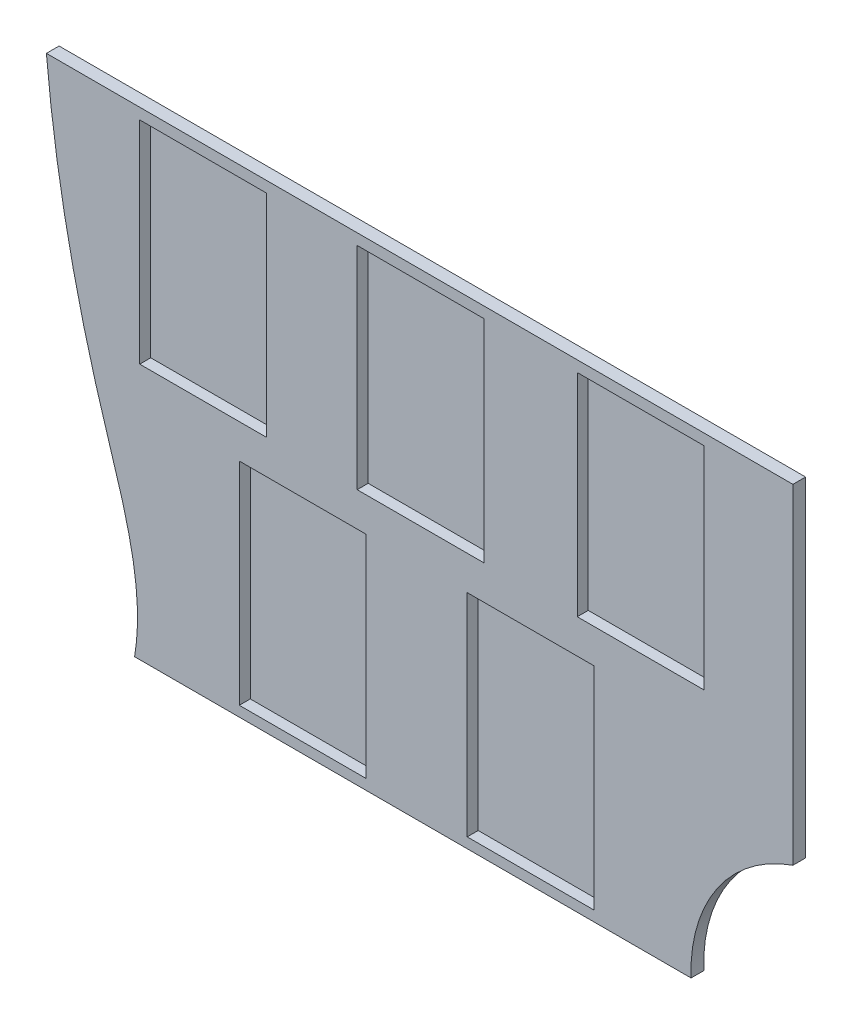
from build123d import *

# Parameters (mm, degrees)
BOSS_EXTRUDE1_DEPTH = 1.5
SKETCH2_W           = 144.766923913
SKETCH2_H           = 30.83722243
CUT_EXTRUDE1_DEPTH  = 65.5
SKETCH3_W           = 15
SKETCH3_H           = 25
CUT_EXTRUDE2_DEPTH  = 1.3


with BuildPart() as part:
    # Sketch1 → Boss-Extrude1 (new body)
    with BuildSketch(Plane.XY):
        with BuildLine():
            Line((0, 0), (65.76731, 0))
            ThreePointArc((65.76731, 0), (68.890778194, 10.762295293), (77.804111714, 17.55461))
            Line((77.804111714, 17.55461), (77.804111714, 76.07506))
            Line((77.804111714, 76.07506), (-10.924558286, 76.07506))
            add(Edge.make_bspline(
                [(-10.924558286, 76.07506), (-11.335216037, 65.701051621), (-10.134883802, 47.610493724), (-4.204795631, 22.570600883), (1.324592934, 7.942603507), (0, 0)],
                knots=[0, 0, 0, 0, 0.403327981, 0.698479283, 1, 1, 1, 1], degree=3))
        make_face()
    extrude(amount=BOSS_EXTRUDE1_DEPTH)

    # Sketch2 → Cut-Extrude1 (cut)
    with BuildSketch(Plane.XY.offset(11.5)):
        with Locations((32.739385879, 71.968611215)):
            Rectangle(SKETCH2_W, SKETCH2_H)
    extrude(amount=-CUT_EXTRUDE1_DEPTH, mode=Mode.SUBTRACT)

    # Sketch3 → Cut-Extrude2 (cut)
    with BuildSketch(Plane.XY.offset(1.5)):
        with Locations((8.104747285, 42.750740974)):
            Rectangle(SKETCH3_W, SKETCH3_H)
        with Locations((33.805332754, 42.750740974)):
            Rectangle(SKETCH3_W, SKETCH3_H)
        with Locations((59.815563831, 42.750740974)):
            Rectangle(SKETCH3_W, SKETCH3_H)
        with Locations((19.871280391, 13.717582368)):
            Rectangle(SKETCH3_W, SKETCH3_H)
        with Locations((46.810448292, 13.717582368)):
            Rectangle(SKETCH3_W, SKETCH3_H)
    extrude(amount=-CUT_EXTRUDE2_DEPTH, mode=Mode.SUBTRACT)


solid = part.part
